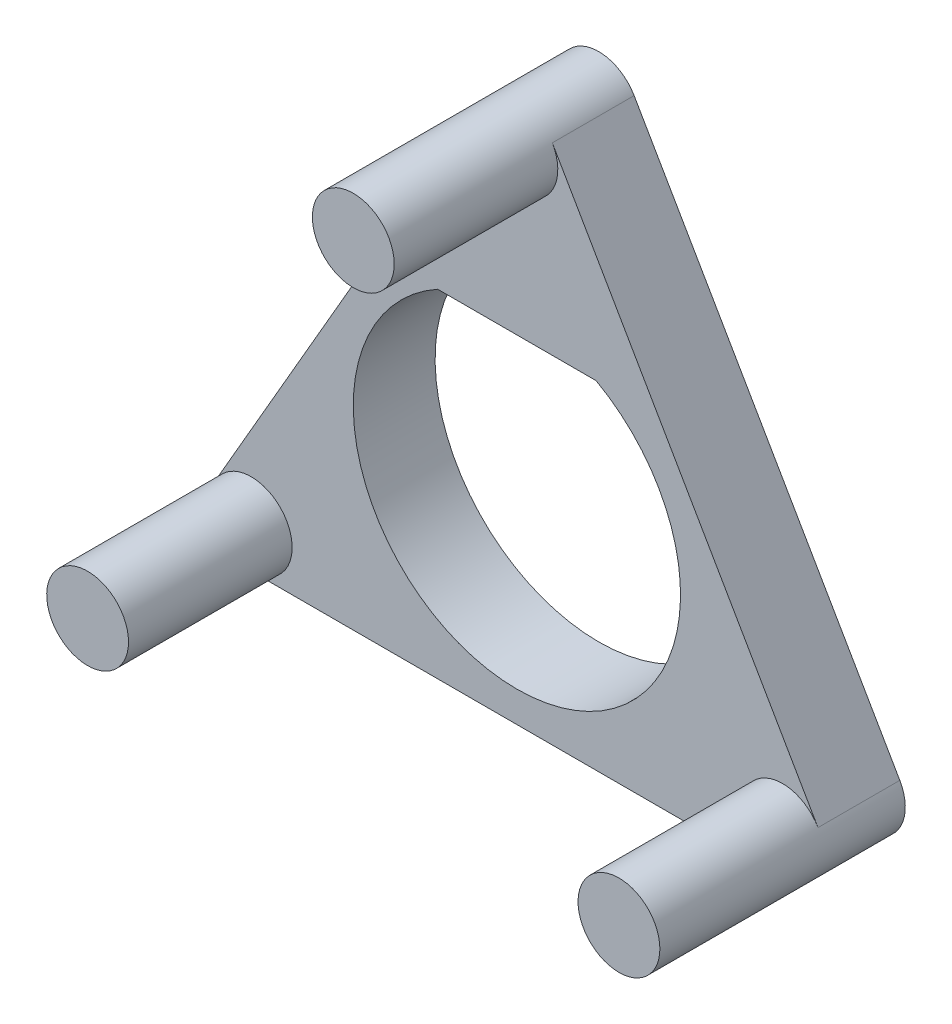
from build123d import *

# Parameters (mm, degrees)
EXTRUDE_1_DEPTH     = 2
SKETCH_2_R          = 1
EXTRUDE_2_DEPTH     = 4
CUT_EXTRUDE_4_DEPTH = 5


with BuildPart() as part:
    # 草图1 → 凸台-拉伸1 (new body)
    with BuildSketch(Plane.XY):
        with BuildLine():
            Line((-7.361215932, 1.5), (-0.866025404, 12.75))
            ThreePointArc((-0.866025404, 12.75), (0, 13.25), (0.866025404, 12.75))
            Line((0.866025404, 12.75), (7.361215932, 1.5))
            ThreePointArc((7.361215932, 1.5), (7.361215932, 0.5), (6.495190528, 0))
            Line((6.495190528, 0), (-6.495190528, 0))
            ThreePointArc((-6.495190528, 0), (-7.361215932, 0.5), (-7.361215932, 1.5))
        make_face()
    extrude(amount=EXTRUDE_1_DEPTH)

    # 草图2 → 凸台-拉伸2 (add)
    with BuildSketch(Plane.XY.offset(2)):
        with Locations(Location((0, 12.25, 0), (0, 0, 150))):
            Circle(SKETCH_2_R)
        with Locations(Location((6.495190528, 1, 0), (0, 0, 270))):
            Circle(SKETCH_2_R)
        with Locations(Location((-6.495190528, 1, 0), (0, 0, 150))):
            Circle(SKETCH_2_R)
    extrude(amount=EXTRUDE_2_DEPTH)

    # 草图3 → 切除-拉伸4 (cut)
    with BuildSketch(Plane.XY.offset(2)):
        with BuildLine():
            Line((-1.936491673, 8.25), (1.936491673, 8.25))
            ThreePointArc((1.936491673, 8.25), (0, 0.75), (-1.936491673, 8.25))
        make_face()
    extrude(amount=-CUT_EXTRUDE_4_DEPTH, mode=Mode.SUBTRACT)


solid = part.part
